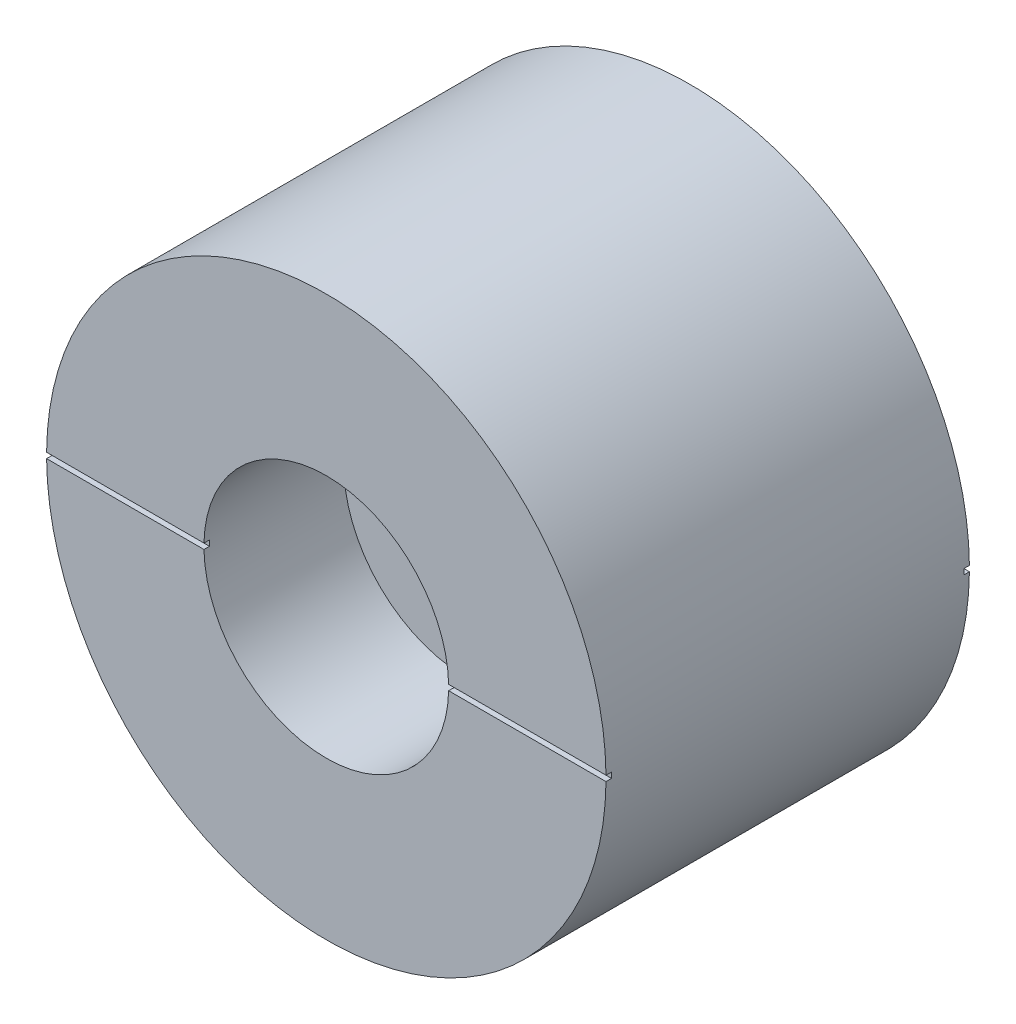
from build123d import *

# Parameters (mm, degrees)
SKETCH1_R                                        = 12.7
BASE_EXTRUDE_DEPTH                               = 16.5
CBORE_FOR_1_4_SOCKET_HEAD_CAP_SCREW1_D           = 6.5278
CBORE_FOR_1_4_SOCKET_HEAD_CAP_SCREW1_CBORE_D     = 11.1125
CBORE_FOR_1_4_SOCKET_HEAD_CAP_SCREW1_CBORE_DEPTH = 6.35
SKETCH4_W                                        = 26.942464066
SKETCH4_H                                        = 0.25
VENT_GROOVE_FRONT_DEPTH                          = 0.25
SKETCH5_W                                        = 27.489916166
SKETCH5_H                                        = 0.25
VENT_GROOVE_BACK_DEPTH                           = 0.25


with BuildPart() as part:
    # Sketch1 → Base-Extrude (new body)
    with BuildSketch(Plane.XY):
        Circle(SKETCH1_R)
    extrude(amount=BASE_EXTRUDE_DEPTH)

    # CBORE for 1/4 Socket Head Cap Screw1 (through all)
    with Locations(Plane(origin=(7.46029001, -0.504629161, 16.5), x_dir=(1, 0, 0), z_dir=(0, 0, 1))):
        with Locations((-7.46029001, 0.504629161)):
            CounterBoreHole(CBORE_FOR_1_4_SOCKET_HEAD_CAP_SCREW1_D / 2, CBORE_FOR_1_4_SOCKET_HEAD_CAP_SCREW1_CBORE_D / 2, CBORE_FOR_1_4_SOCKET_HEAD_CAP_SCREW1_CBORE_DEPTH)

    # Sketch4 → Vent Groove Front (cut)
    with BuildSketch(Plane.XY.offset(16.5)):
        with Locations((0.293277911, 0)):
            Rectangle(SKETCH4_W, SKETCH4_H)
    extrude(amount=-VENT_GROOVE_FRONT_DEPTH, mode=Mode.SUBTRACT)

    # Sketch5 → Vent Groove Back (cut)
    with BuildSketch(Plane(origin=(0, 0, 0), x_dir=(-1, 0, 0), z_dir=(0, 0, -1))):
        with Locations((0.254174189, 0)):
            Rectangle(SKETCH5_W, SKETCH5_H)
    extrude(amount=-VENT_GROOVE_BACK_DEPTH, mode=Mode.SUBTRACT)


solid = part.part
